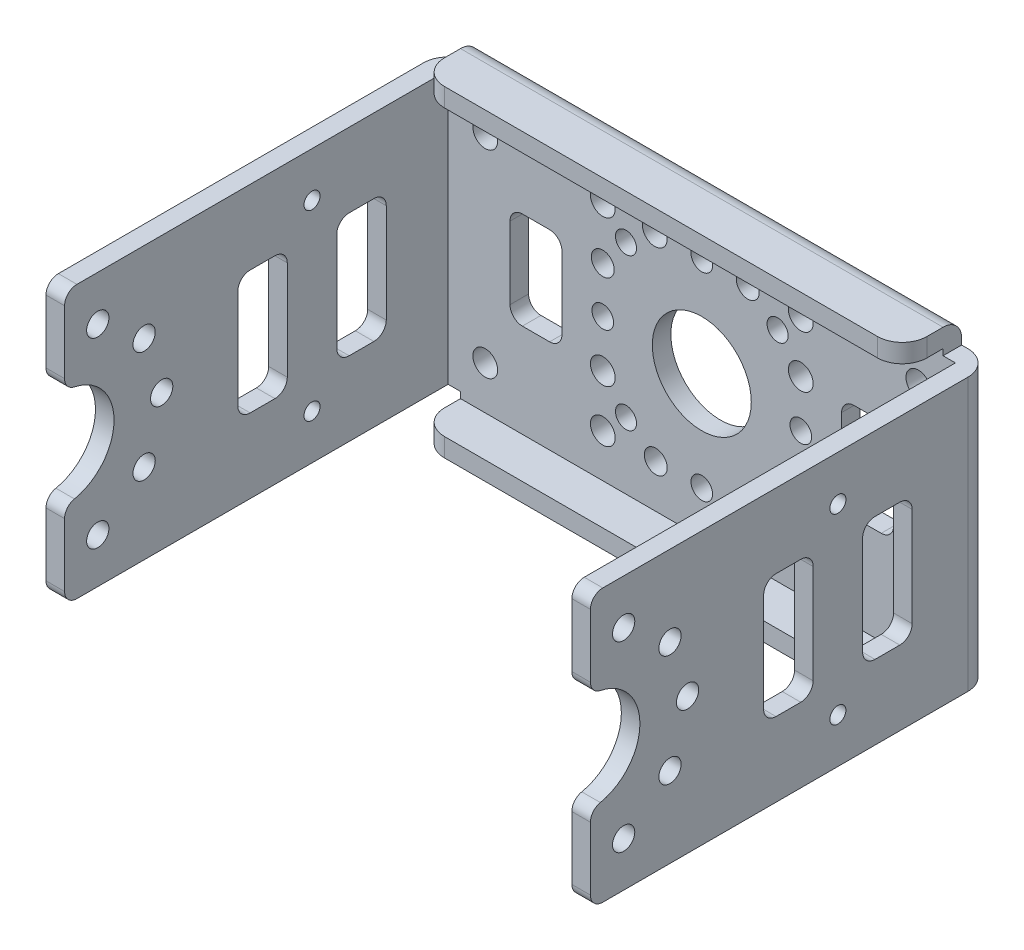
from build123d import *

# Parameters (mm, degrees)
SKETCH1_W            = 39
SKETCH1_H            = 26
SKETCH1_R            = 1
SKETCH1_R_2          = 0.925
SKETCH1_R_3          = 0.875
SKETCH1_R_4          = 0.85
SKETCH1_R_5          = 4
BOSS_EXTRUDE1_DEPTH  = 1.5
SKETCH2_W            = 1.5
SKETCH2_H            = 22
BOSS_EXTRUDE2_DEPTH  = 1
SKETCH3_R            = 0.9
SKETCH3_R_2          = 0.65
BOSS_EXTRUDE3_DEPTH  = 1.5
FILLET1_R            = 2
FILLET2_R            = 1
FILLET1_OF_MIRROR1_R = 2
FILLET2_OF_MIRROR1_R = 1
SKETCH4_W            = 39
SKETCH4_H            = 4.8
BOSS_EXTRUDE4_DEPTH  = 1.5
FILLET3_R            = 2
FILLET4_R            = 1.5
SKETCH5_W            = 39
SKETCH5_H            = 4.8
BOSS_EXTRUDE5_DEPTH  = 1.5
FILLET5_R            = 2
FILLET6_R            = 1.5


with BuildPart() as part:
    # Sketch1 → Boss-Extrude1 (new body)
    with BuildSketch(Plane.XY):
        Rectangle(SKETCH1_W, SKETCH1_H)
        with Locations((-17.5, -8)):
            Circle(SKETCH1_R, mode=Mode.SUBTRACT)
        with Locations((-8, -8)):
            Circle(SKETCH1_R, mode=Mode.SUBTRACT)
        with Locations((-3.72, -8)):
            Circle(SKETCH1_R_2, mode=Mode.SUBTRACT)
        with Locations((0, -8)):
            Circle(SKETCH1_R_3, mode=Mode.SUBTRACT)
        with Locations((-6.12616703, -6.12616703)):
            Circle(SKETCH1_R_4, mode=Mode.SUBTRACT)
        with Locations((-8, -3.8)):
            Circle(SKETCH1_R, mode=Mode.SUBTRACT)
        with Locations((3.8, -8)):
            Circle(SKETCH1_R, mode=Mode.SUBTRACT)
        with Locations((8, -8)):
            Circle(SKETCH1_R, mode=Mode.SUBTRACT)
        with Locations((17.5, -8)):
            Circle(SKETCH1_R, mode=Mode.SUBTRACT)
        with Locations((6.12616703, -6.12616703)):
            Circle(SKETCH1_R_4, mode=Mode.SUBTRACT)
        with Locations((8, -3.72)):
            Circle(SKETCH1_R_2, mode=Mode.SUBTRACT)
        with Locations((8, 0)):
            Circle(SKETCH1_R_3, mode=Mode.SUBTRACT)
        with BuildLine():
            ThreePointArc((11.3, 2.925), (11.592893219, 3.632106781), (12.3, 3.925))
            Line((12.3, 3.925), (14.5, 3.925))
            ThreePointArc((14.5, 3.925), (15.207106781, 3.632106781), (15.5, 2.925))
            Line((15.5, 2.925), (15.5, -2.925))
            ThreePointArc((15.5, -2.925), (15.207106781, -3.632106781), (14.5, -3.925))
            Line((14.5, -3.925), (12.3, -3.925))
            ThreePointArc((12.3, -3.925), (11.592893219, -3.632106781), (11.3, -2.925))
            Line((11.3, -2.925), (11.3, 2.925))
        make_face(mode=Mode.SUBTRACT)
        with BuildLine():
            Line((-14.5, 3.925), (-12.3, 3.925))
            ThreePointArc((-12.3, 3.925), (-11.592893219, 3.632106781), (-11.3, 2.925))
            Line((-11.3, 2.925), (-11.3, -2.925))
            ThreePointArc((-11.3, -2.925), (-11.592893219, -3.632106781), (-12.3, -3.925))
            Line((-12.3, -3.925), (-14.5, -3.925))
            ThreePointArc((-14.5, -3.925), (-15.207106781, -3.632106781), (-15.5, -2.925))
            Line((-15.5, -2.925), (-15.5, 2.925))
            ThreePointArc((-15.5, 2.925), (-15.207106781, 3.632106781), (-14.5, 3.925))
        make_face(mode=Mode.SUBTRACT)
        with Locations((-8, 0)):
            Circle(SKETCH1_R_3, mode=Mode.SUBTRACT)
        Circle(SKETCH1_R_5, mode=Mode.SUBTRACT)
        with Locations((-8, 3.72)):
            Circle(SKETCH1_R_2, mode=Mode.SUBTRACT)
        with Locations((-6.12616703, 6.12616703)):
            Circle(SKETCH1_R_4, mode=Mode.SUBTRACT)
        with Locations((-17.5, 8)):
            Circle(SKETCH1_R, mode=Mode.SUBTRACT)
        with Locations((-8, 8)):
            Circle(SKETCH1_R, mode=Mode.SUBTRACT)
        with Locations((-3.8, 8)):
            Circle(SKETCH1_R, mode=Mode.SUBTRACT)
        with Locations((8, 3.8)):
            Circle(SKETCH1_R, mode=Mode.SUBTRACT)
        with Locations((6.12616703, 6.12616703)):
            Circle(SKETCH1_R_4, mode=Mode.SUBTRACT)
        with Locations((0, 8)):
            Circle(SKETCH1_R_3, mode=Mode.SUBTRACT)
        with Locations((3.72, 8)):
            Circle(SKETCH1_R_2, mode=Mode.SUBTRACT)
        with Locations((8, 8)):
            Circle(SKETCH1_R, mode=Mode.SUBTRACT)
        with Locations((17.5, 8)):
            Circle(SKETCH1_R, mode=Mode.SUBTRACT)
    extrude(amount=BOSS_EXTRUDE1_DEPTH)

    # Sketch2 → Boss-Extrude2 (add)
    with BuildSketch(Plane.ZY.offset(19.5)):
        with Locations((0.75, 0)):
            Rectangle(SKETCH2_W, SKETCH2_H)
    boss_extrude2 = extrude(amount=BOSS_EXTRUDE2_DEPTH)

    # Sketch3 → Boss-Extrude3 (add)
    with BuildSketch(Plane.ZY.offset(20.5)):
        with BuildLine():
            Line((0, 11), (32.5, 11))
            Line((32.5, 11), (32.5, 4))
            ThreePointArc((32.5, 4), (28.5, 0), (32.5, -4))
            Line((32.5, -4), (32.5, -11))
            Line((32.5, -11), (0, -11))
            Line((0, -11), (0, 11))
        make_face()
        with Locations((24.65, 0)):
            Circle(SKETCH3_R, mode=Mode.SUBTRACT)
        with Locations((26.069656452, 4.502575025)):
            Circle(SKETCH3_R, mode=Mode.SUBTRACT)
        with Locations((29.815141875, 7.376587073)):
            Circle(SKETCH3_R, mode=Mode.SUBTRACT)
        with Locations((29.815141875, -7.376587073)):
            Circle(SKETCH3_R, mode=Mode.SUBTRACT)
        with Locations((26.069656452, -4.502575025)):
            Circle(SKETCH3_R, mode=Mode.SUBTRACT)
        with Locations((12.5, 7.376587073)):
            Circle(SKETCH3_R_2, mode=Mode.SUBTRACT)
        with Locations((12.5, -7.376587073)):
            Circle(SKETCH3_R_2, mode=Mode.SUBTRACT)
        with BuildLine():
            Line((15.5, -5), (17.5, -5))
            ThreePointArc((17.5, -5), (18.207106781, -4.707106781), (18.5, -4))
            Line((18.5, -4), (18.5, 4))
            ThreePointArc((18.5, 4), (18.207106781, 4.707106781), (17.5, 5))
            Line((17.5, 5), (15.5, 5))
            ThreePointArc((15.5, 5), (14.792893219, 4.707106781), (14.5, 4))
            Line((14.5, 4), (14.5, -4))
            ThreePointArc((14.5, -4), (14.792893219, -4.707106781), (15.5, -5))
        make_face(mode=Mode.SUBTRACT)
        with BuildLine():
            Line((7.5, 5), (9.5, 5))
            ThreePointArc((9.5, 5), (10.207106781, 4.707106781), (10.5, 4))
            Line((10.5, 4), (10.5, -4))
            ThreePointArc((10.5, -4), (10.207106781, -4.707106781), (9.5, -5))
            Line((9.5, -5), (7.5, -5))
            ThreePointArc((7.5, -5), (6.792893219, -4.707106781), (6.5, -4))
            Line((6.5, -4), (6.5, 4))
            ThreePointArc((6.5, 4), (6.792893219, 4.707106781), (7.5, 5))
        make_face(mode=Mode.SUBTRACT)
    boss_extrude3 = extrude(amount=BOSS_EXTRUDE3_DEPTH)

    # Fillet1
    fillet1_edges = [part.edges().sort_by_distance(p)[0] for p in [
        (-22, 0, 0),
    ]]
    fillet(fillet1_edges, radius=FILLET1_R)

    # Fillet2
    fillet2_edges = [part.edges().sort_by_distance(p)[0] for p in [
        (-21.25, 11, 32.5),
        (-21.25, 4, 32.5),
        (-21.25, -4, 32.5),
        (-21.25, -11, 32.5),
    ]]
    fillet(fillet2_edges, radius=FILLET2_R)

    # Mirror1: Boss-Extrude2, Boss-Extrude3 across plane
    add(boss_extrude2.mirror(Plane(origin=(0, 0, 0), x_dir=(0, 0, 1), z_dir=(1, 0, 0))))
    add(boss_extrude3.mirror(Plane(origin=(0, 0, 0), x_dir=(0, 0, 1), z_dir=(1, 0, 0))))

    # Fillet1 of Mirror1
    fillet1_of_mirror1_edges = [part.edges().sort_by_distance(p)[0] for p in [
        (22, 0, 0),
    ]]
    fillet(fillet1_of_mirror1_edges, radius=FILLET1_OF_MIRROR1_R)

    # Fillet2 of Mirror1
    fillet2_of_mirror1_edges = [part.edges().sort_by_distance(p)[0] for p in [
        (21.25, 11, 32.5),
        (21.25, 4, 32.5),
        (21.25, -4, 32.5),
        (21.25, -11, 32.5),
    ]]
    fillet(fillet2_of_mirror1_edges, radius=FILLET2_OF_MIRROR1_R)

    # Sketch4 → Boss-Extrude4 (add)
    with BuildSketch(Plane(origin=(0, 13, 0), x_dir=(1, 0, 0), z_dir=(0, 1, 0))):
        with Locations((0, -2.4)):
            Rectangle(SKETCH4_W, SKETCH4_H)
    extrude(amount=-BOSS_EXTRUDE4_DEPTH)

    # Fillet3
    fillet3_edges = [part.edges().sort_by_distance(p)[0] for p in [
        (19.5, 12.25, 4.8),
        (-19.5, 12.25, 4.8),
    ]]
    fillet(fillet3_edges, radius=FILLET3_R)

    # Fillet4
    fillet4_edges = [part.edges().sort_by_distance(p)[0] for p in [
        (0, 13, 0),
    ]]
    fillet(fillet4_edges, radius=FILLET4_R)

    # Sketch5 → Boss-Extrude5 (add)
    with BuildSketch(Plane.XZ.offset(13)):
        with Locations((0, 2.4)):
            Rectangle(SKETCH5_W, SKETCH5_H)
    extrude(amount=-BOSS_EXTRUDE5_DEPTH)

    # Fillet5
    fillet5_edges = [part.edges().sort_by_distance(p)[0] for p in [
        (-19.5, -12.25, 4.8),
        (19.5, -12.25, 4.8),
    ]]
    fillet(fillet5_edges, radius=FILLET5_R)

    # Fillet6
    fillet6_edges = [part.edges().sort_by_distance(p)[0] for p in [
        (0, -13, 0),
    ]]
    fillet(fillet6_edges, radius=FILLET6_R)


solid = part.part
